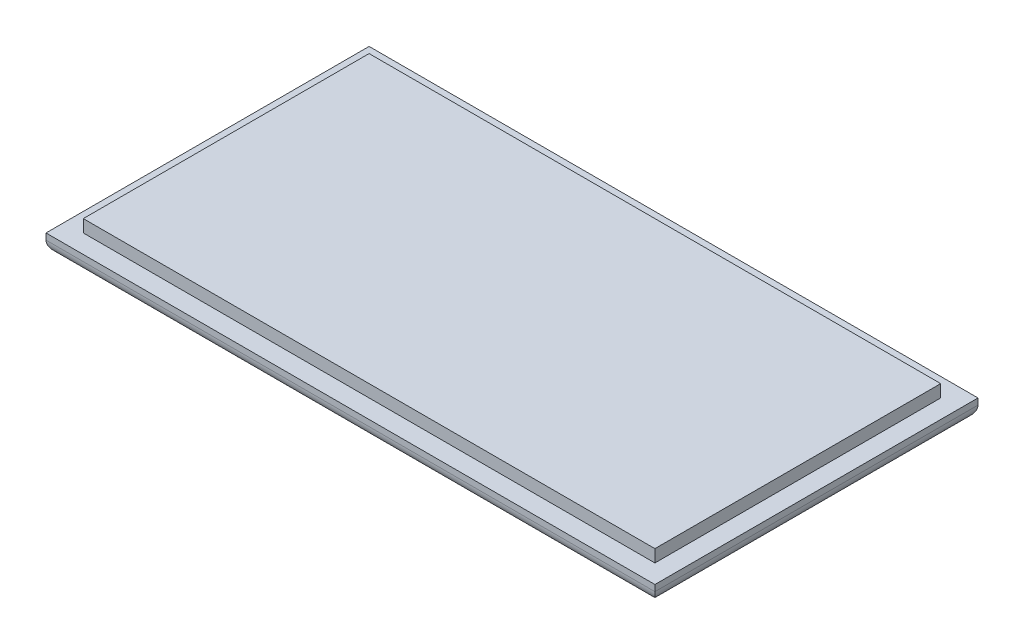
from build123d import *

# Parameters (mm, degrees)
SKETCH_1_W      = 49
SKETCH_1_H      = 26
EXTRUDE_1_DEPTH = 1.5
SKETCH_2_W      = 46
SKETCH_2_H      = 23
EXTRUDE_2_DEPTH = 1
FILLET_1_R      = 1


with BuildPart() as part:
    # 草图1 → 凸台-拉伸1 (new body)
    with BuildSketch(Plane(origin=(0, 0, 0), x_dir=(1, 0, 0), z_dir=(0, 1, 0))):
        Rectangle(SKETCH_1_W, SKETCH_1_H)
    extrude(amount=EXTRUDE_1_DEPTH)

    # 草图2 → 凸台-拉伸2 (add)
    with BuildSketch(Plane(origin=(0, 1.5, 0), x_dir=(1, 0, 0), z_dir=(0, 1, 0))):
        Rectangle(SKETCH_2_W, SKETCH_2_H)
    extrude(amount=EXTRUDE_2_DEPTH)

    # 圆角1
    fillet_1_edges = [part.edges().sort_by_distance(p)[0] for p in [
        (0, 0, 13),
        (-24.5, 0, 0),
        (0, 0, -13),
        (24.5, 0, 0),
    ]]
    fillet(fillet_1_edges, radius=FILLET_1_R)


solid = part.part
